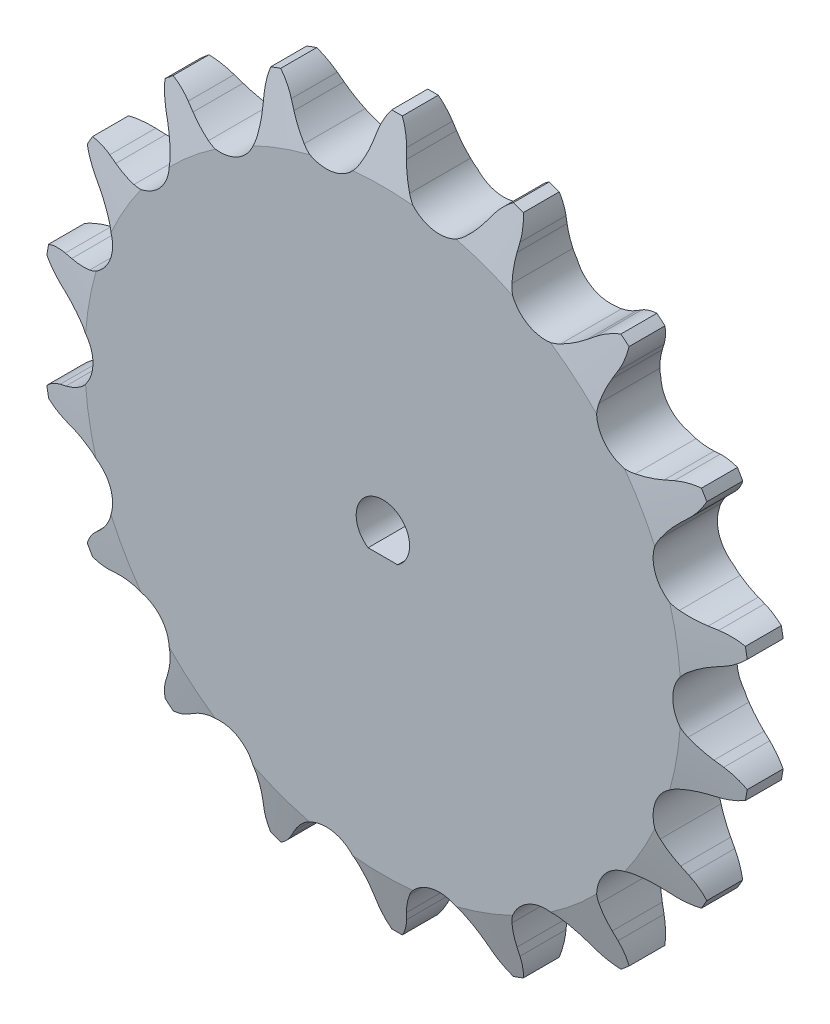
from build123d import *

# Parameters (mm, degrees)
CUT_EXTRUDE1_DEPTH      = 57.433095329
CIRPATTERN1_COUNT       = 18
CUT_EXTRUDE2_DEPTH      = 57.077204718
CUT_EXTRUDE2_DEPTH_BACK = 57.077204718
SKETCH3_OUTSIDE_W       = 103.064
SKETCH3_OUTSIDE_H       = 104.076
SKETCH3_OUTSIDE_R       = 39.878


with BuildPart() as part:
    # Sketch1 → Revolve1 (revolve)
    with BuildSketch(Plane(origin=(0, 0, 0), x_dir=(0, 0, -1), z_dir=(1, 0, 0)), mode=Mode.PRIVATE) as revolve1_sk:
        Polygon((3.6068, 0), (-3.6068, 0), (-3.6068, 33.472639555), (-2.0193, 39.822639555), (2.0193, 39.822639555), (3.6068, 33.472639555), align=None)
    revolve(revolve1_sk.sketch.rotate(Axis((0, 0, -3.6068), (0, 0, 1)), 90), axis=Axis((0, 0, -3.6068), (0, 0, 1)))

    # Sketch0 → Cut-Extrude1 (cut, symmetric)
    with BuildSketch(Plane.XY):
        with BuildLine():
            Line((11.30390338, -35.832051412), (10.78002486, -35.038887396))
            ThreePointArc((10.78002486, -35.038887396), (9.9673727, -33.966963342), (9.022686796, -33.009365696))
            ThreePointArc((9.022686796, -33.009365696), (5.651880148, -32.053405127), (2.811315785, -34.104597993))
            ThreePointArc((2.811315785, -34.104597993), (2.251119095, -35.327547043), (1.854095476, -36.612769574))
            Line((1.854095476, -36.612769574), (1.633088767, -37.537276953))
            ThreePointArc((1.633088767, -37.537276953), (-1.028147616, -41.415236484), (-5.601279879, -42.513967807))
            ThreePointArc((-5.601279879, -42.513967807), (7.446271558, -42.229904509), (19.804114732, -38.034311281))
            ThreePointArc((19.804114732, -38.034311281), (15.130987846, -38.565944917), (11.30390338, -35.832051412))
        make_face()
    cut_extrude1 = extrude(amount=CUT_EXTRUDE1_DEPTH, both=True, mode=Mode.SUBTRACT)

    # CirPattern1: Cut-Extrude1 ×18 about axis
    cirpattern1_axis = Axis((0, 0, 0), (0, 0, 1))
    for i in range(1, CIRPATTERN1_COUNT):
        add(cut_extrude1.rotate(cirpattern1_axis, i * 360 / CIRPATTERN1_COUNT), mode=Mode.SUBTRACT)

    # Sketch3 outside → Cut-Extrude2 (cut, two sides: drawn at the far end of the back side and taken through both)
    # profile 1 of 2: a face of its own
    with BuildSketch(Plane.XY.offset(-CUT_EXTRUDE2_DEPTH_BACK)):
        Rectangle(SKETCH3_OUTSIDE_W, SKETCH3_OUTSIDE_H)
        Circle(SKETCH3_OUTSIDE_R, mode=Mode.SUBTRACT)
    # profile 2 of 2: a face of its own
    with BuildSketch(Plane.XY.offset(-CUT_EXTRUDE2_DEPTH_BACK)):
        with BuildLine():
            Line((-1.658312275, -2.50000008), (1.658312275, -2.50000008))
            ThreePointArc((1.658312275, -2.50000008), (0, 3), (-1.658312275, -2.50000008))
        make_face()
    extrude(amount=CUT_EXTRUDE2_DEPTH + CUT_EXTRUDE2_DEPTH_BACK, mode=Mode.SUBTRACT)


solid = part.part
